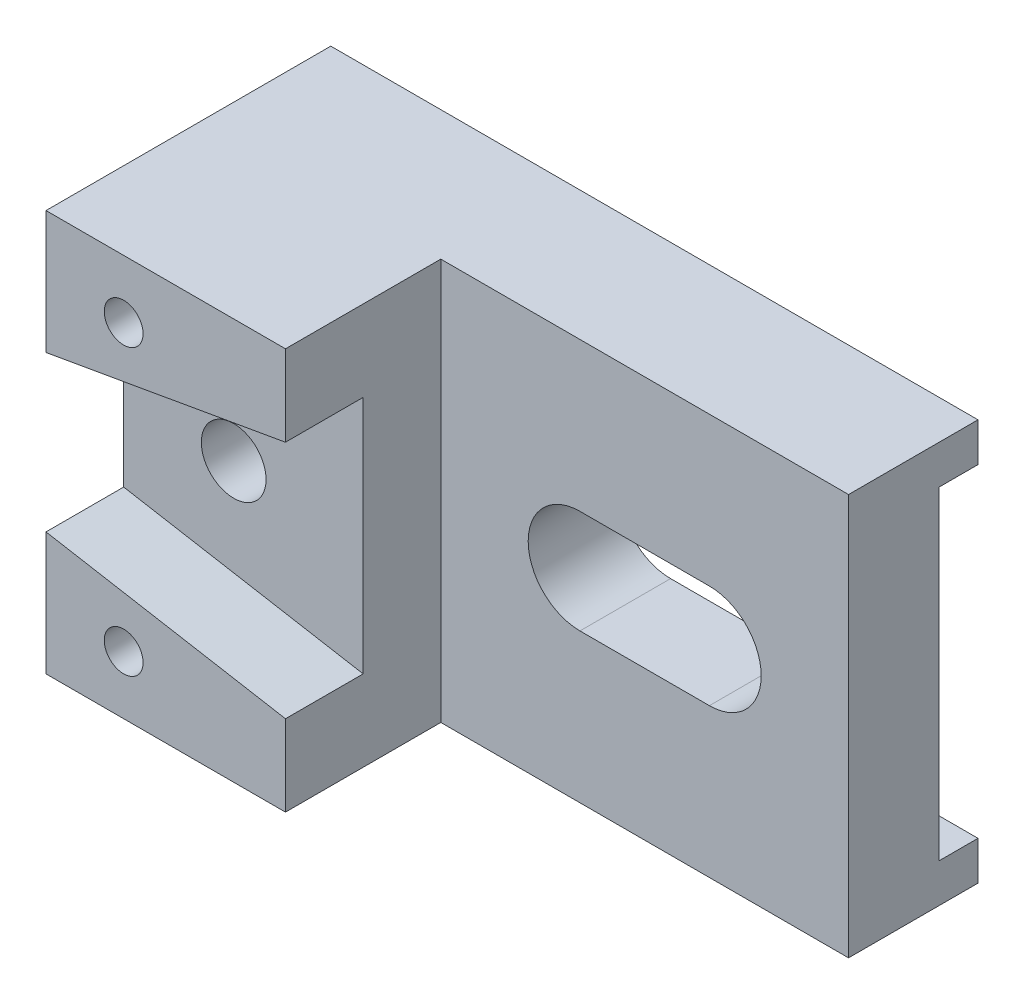
from build123d import *

# Parameters (mm, degrees)
SKETCH1_W           = 100
SKETCH1_H           = 62
BOSS_EXTRUDE1_DEPTH = 20
SKETCH2_W           = 37
SKETCH2_H           = 62
BOSS_EXTRUDE2_DEPTH = 24
CUT_EXTRUDE2_DEPTH  = 12
SKETCH4_R           = 5
CUT_EXTRUDE3_DEPTH  = 33
SKETCH5_R           = 3
CUT_EXTRUDE4_DEPTH  = 20
SKETCH12_R          = 3
CUT_EXTRUDE12_DEPTH = 20
CUT_EXTRUDE13_DEPTH = 21
SKETCH14_W          = 6
SKETCH14_H          = 50
CUT_EXTRUDE14_DEPTH = 101


with BuildPart() as part:
    # Sketch1 → Boss-Extrude1 (new body)
    with BuildSketch(Plane.XY):
        Rectangle(SKETCH1_W, SKETCH1_H)
    extrude(amount=BOSS_EXTRUDE1_DEPTH)

    # Sketch2 → Boss-Extrude2 (add)
    with BuildSketch(Plane.XY.offset(20)):
        with Locations((-31.5, 0)):
            Rectangle(SKETCH2_W, SKETCH2_H)
    extrude(amount=BOSS_EXTRUDE2_DEPTH)

    # Sketch3 → Cut-Extrude2 (cut)
    with BuildSketch(Plane.XY.offset(44)):
        Polygon((-50, 12), (-13, 18.5), (-13, -18.5), (-50, -12), align=None)
    extrude(amount=-CUT_EXTRUDE2_DEPTH, mode=Mode.SUBTRACT)

    # Sketch4 → Cut-Extrude3 (cut, through all)
    with BuildSketch(Plane.XY.offset(32)):
        with Locations((-33, 0)):
            Circle(SKETCH4_R)
    extrude(amount=-CUT_EXTRUDE3_DEPTH, mode=Mode.SUBTRACT)

    # Sketch5 → Cut-Extrude4 (cut)
    with BuildSketch(Plane.XY.offset(44)):
        with Locations((-38, 22)):
            Circle(SKETCH5_R)
    extrude(amount=-CUT_EXTRUDE4_DEPTH, mode=Mode.SUBTRACT)

    # Sketch12 → Cut-Extrude12 (cut)
    with BuildSketch(Plane.XY.offset(44)):
        with Locations((-38, -22)):
            Circle(SKETCH12_R)
    extrude(amount=-CUT_EXTRUDE12_DEPTH, mode=Mode.SUBTRACT)

    # Sketch13 → Cut-Extrude13 (cut, through all)
    with BuildSketch(Plane.XY.offset(20)):
        with BuildLine():
            Line((8.5, 8), (28.5, 8))
            ThreePointArc((28.5, 8), (36.5, 0), (28.5, -8))
            Line((28.5, -8), (8.5, -8))
            ThreePointArc((8.5, -8), (0.5, 0), (8.5, 8))
        make_face()
    extrude(amount=-CUT_EXTRUDE13_DEPTH, mode=Mode.SUBTRACT)

    # Sketch14 → Cut-Extrude14 (cut, through all)
    with BuildSketch(Plane(origin=(50, 0, 0), x_dir=(0, 0, -1), z_dir=(1, 0, 0))):
        with Locations((-3, 0)):
            Rectangle(SKETCH14_W, SKETCH14_H)
    extrude(amount=-CUT_EXTRUDE14_DEPTH, mode=Mode.SUBTRACT)


solid = part.part
